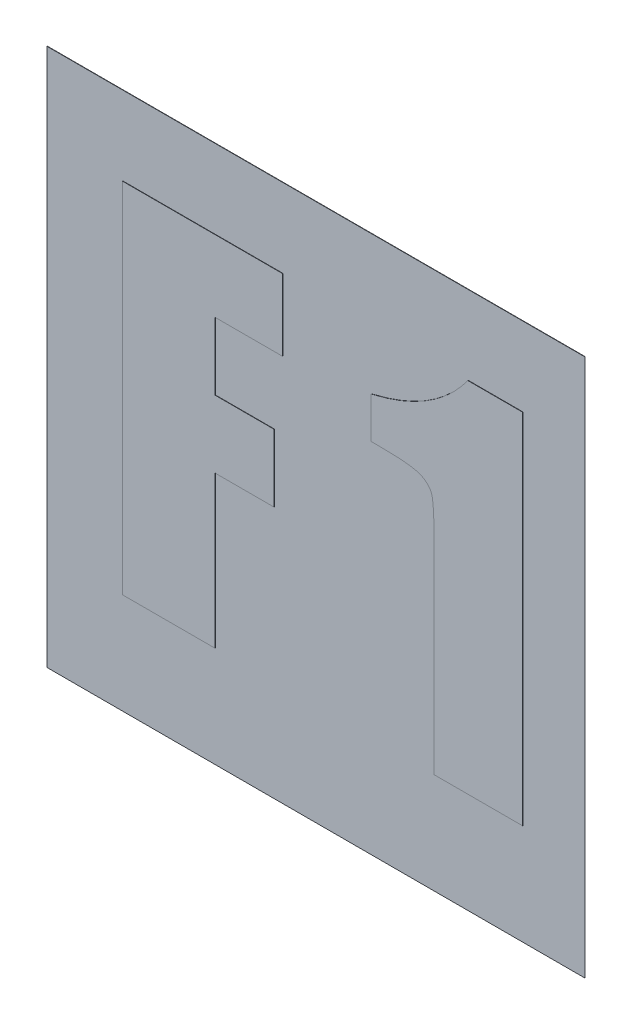
from build123d import *

# Parameters (mm, degrees)
SKETCH1_W           = 15
SKETCH1_H           = 15
BASE_EXTRUDE_DEPTH  = 0.01
BOSS_EXTRUDE1_DEPTH = 0.01


with BuildPart() as part:
    # Sketch1 → Base-Extrude (new body)
    with BuildSketch(Plane.XY):
        Rectangle(SKETCH1_W, SKETCH1_H)
    extrude(amount=BASE_EXTRUDE_DEPTH)

    # Sketch3 → Boss-Extrude1 (add)
    with BuildSketch(Plane.XY.offset(0.01)):
        Polygon((-5.384794802, 5.306205085), (-0.919413872, 5.306205085), (-0.919413872, 3.308534669), (-2.799574264, 3.308534669), (-2.799574264, 1.428374278), (-1.154433921, 1.428374278), (-1.154433921, -0.451786113), (-2.799574264, -0.451786113), (-2.799574264, -4.682146994), (-5.384794802, -4.682146994), align=None)
        with BuildLine():
            Line((5.778657522, 5.306205085), (5.778657522, -4.682146994))
            Line((5.778657522, -4.682146994), (3.310947008, -4.682146994))
            Line((3.310947008, -4.682146994), (3.310947008, 0.631509425))
            add(Edge.make_bspline(
                [(3.310947008, 0.631509425), (3.311365342, 0.722705919), (3.312157129, 0.895315198), (3.306902941, 1.140099359), (3.305115083, 1.356227307), (3.29663727, 1.543462875), (3.289754242, 1.702011057), (3.28210286, 1.832060335), (3.268629119, 1.932937084), (3.253452809, 2.029125513), (3.218364299, 2.126245543), (3.149902887, 2.224742427), (3.055027036, 2.30592508), (2.957850387, 2.361661392), (2.86133248, 2.397721466), (2.767354753, 2.419754241), (2.654999623, 2.442924218), (2.522270481, 2.457900628), (2.369827486, 2.470808129), (2.197743036, 2.479518793), (2.006133688, 2.485064416), (1.87206589, 2.485654626), (1.801677632, 2.485964498)],
                knots=[0, 0, 0, 0, 0.000273578, 0.000517806, 0.000734496, 0.000921922, 0.001079997, 0.001210682, 0.001312482, 0.001385234, 0.001502572, 0.001618697, 0.001740987, 0.001874214, 0.001952652, 0.002049287, 0.002163436, 0.002296663, 0.0024496, 0.002622437, 0.00281347, 0.003024629, 0.003024629, 0.003024629, 0.003024629], degree=3))
            Line((1.801677632, 2.485964498), (1.548296642, 2.485964498))
            Line((1.548296642, 2.485964498), (1.548296642, 3.631687237))
            add(Edge.make_bspline(
                [(1.548296642, 3.631687237), (1.692768945, 3.668008672), (1.97564938, 3.739126964), (2.381568254, 3.881832395), (2.761461914, 4.050628674), (3.11452453, 4.24679379), (3.440527614, 4.470451829), (3.738971557, 4.721598196), (4.0130797, 4.998312096), (4.171649736, 5.203494338), (4.251027204, 5.306205085)],
                knots=[0, 0, 0, 0, 0.000446718, 0.000874686, 0.001288928, 0.001692505, 0.002084661, 0.002473028, 0.002861244, 0.003250366, 0.003250366, 0.003250366, 0.003250366], degree=3))
            Line((4.251027204, 5.306205085), (5.778657522, 5.306205085))
        make_face()
    extrude(amount=BOSS_EXTRUDE1_DEPTH)


solid = part.part
